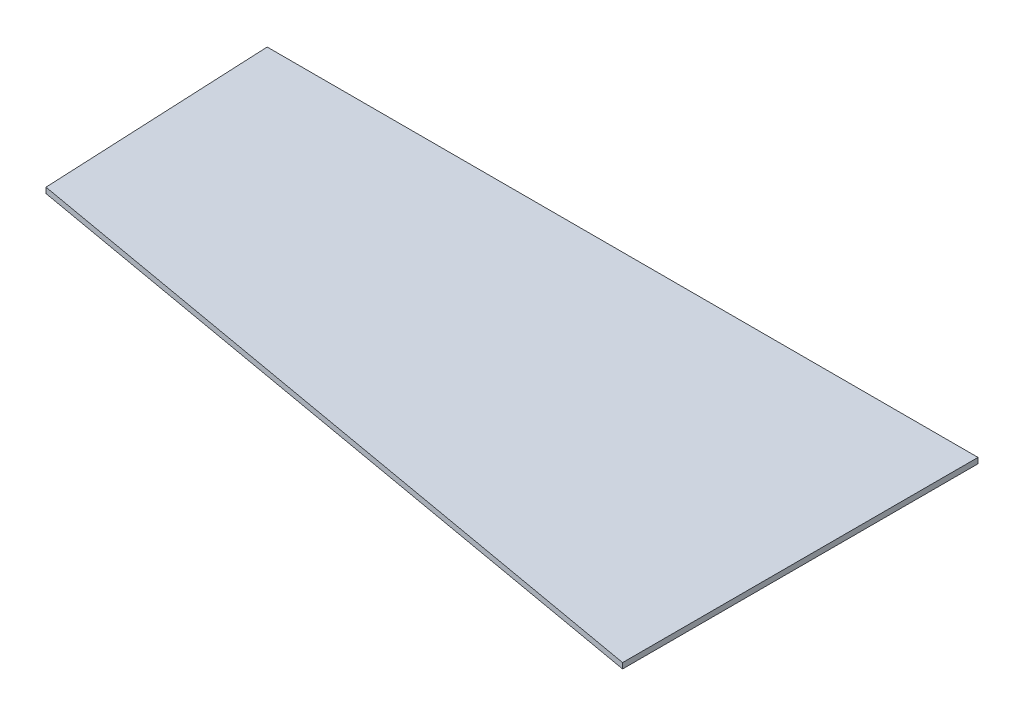
from build123d import *

# Parameters (mm, degrees)
BOSS_EXTRUDE1_DEPTH = 19.05


with BuildPart() as part:
    # Sketch1 → Boss-Extrude1 (new body)
    with BuildSketch(Plane(origin=(0, 0, 0), x_dir=(1, 0, 0), z_dir=(0, 1, 0))):
        Polygon((0, 0), (0, 1219.2), (-2438.4, 1219.2), (-2401.355224945, 423.423716423), align=None)
    extrude(amount=BOSS_EXTRUDE1_DEPTH)


solid = part.part
